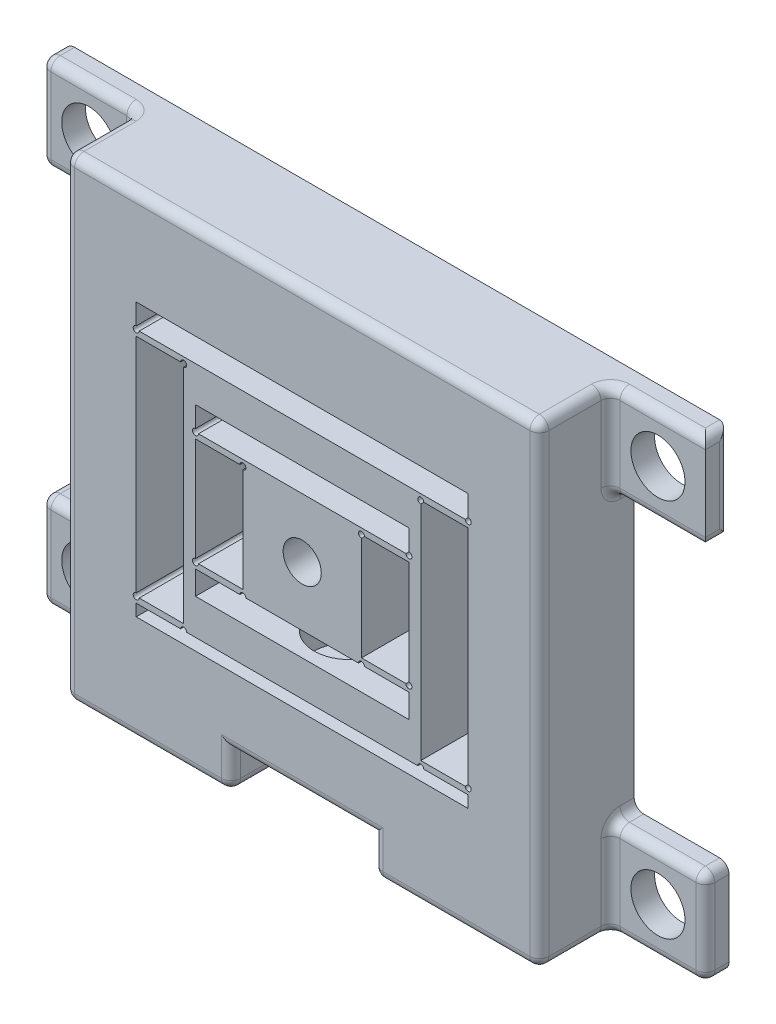
from build123d import *

# Parameters (mm, degrees)
SKETCH1_W           = 63.5
SKETCH1_H           = 63.5
BOSS_EXTRUDE1_DEPTH = 12.7
SKETCH2_W           = 28.575
SKETCH2_H           = 22.225
SKETCH2_W_2         = 15.875
SKETCH2_H_2         = 15.875
CUT_EXTRUDE1_DEPTH  = 13.7
SKETCH3_W           = 44.45
SKETCH3_H           = 36.5125
SKETCH3_W_2         = 31.75
SKETCH3_H_2         = 31.75
CUT_EXTRUDE2_DEPTH  = 13.7
SKETCH4_W           = 6.35
SKETCH4_H           = 0.8
BOSS_EXTRUDE3_DEPTH = 12.7
SKETCH5_R           = 0.399999962
CUT_EXTRUDE3_DEPTH  = 13.7
SKETCH6_R           = 4.2164
CUT_EXTRUDE4_DEPTH  = 14.2875
CUT_EXTRUDE6_REACH  = 49.625
SKETCH8_R           = 4.7625
SKETCH10_R          = 2.5527
CUT_EXTRUDE8_DEPTH  = 13.7
CUT_EXTRUDE9_START  = -7.62
SKETCH12_R          = 1.1303
CUT_EXTRUDE9_DEPTH  = 31.070640303
SKETCH19_W          = 12.7
SKETCH19_H          = 12.7
BOSS_EXTRUDE4_DEPTH = 3.175
SKETCH9_R           = 3.6195
CUT_EXTRUDE7_DEPTH  = 13.7
FILLET3_R           = 1.27
SKETCH20_W          = 19.05
SKETCH20_H          = 12.7
CUT_EXTRUDE10_DEPTH = 5.08
FILLET4_R           = 1.27


with BuildPart() as part:
    # Sketch1 → Boss-Extrude1 (new body)
    with BuildSketch(Plane.XY):
        Rectangle(SKETCH1_W, SKETCH1_H)
    extrude(amount=BOSS_EXTRUDE1_DEPTH)

    # Sketch2 → Cut-Extrude1 (cut, through all)
    with BuildSketch(Plane.XY.offset(12.7)):
        Rectangle(SKETCH2_W, SKETCH2_H)
        Rectangle(SKETCH2_W_2, SKETCH2_H_2, mode=Mode.SUBTRACT)
    extrude(amount=-CUT_EXTRUDE1_DEPTH, mode=Mode.SUBTRACT)

    # Sketch3 → Cut-Extrude2 (cut, through all)
    with BuildSketch(Plane.XY.offset(12.7)):
        with Locations((0, 0.79375)):
            Rectangle(SKETCH3_W, SKETCH3_H)
        Rectangle(SKETCH3_W_2, SKETCH3_H_2, mode=Mode.SUBTRACT)
    extrude(amount=-CUT_EXTRUDE2_DEPTH, mode=Mode.SUBTRACT)

    # Sketch4 → Boss-Extrude3 (add)
    with BuildSketch(Plane.XY.offset(12.7)):
        with Locations((-11.1125, 7.5375)):
            Rectangle(SKETCH4_W, SKETCH4_H)
        with Locations((-19.05, 15.475)):
            Rectangle(SKETCH4_W, SKETCH4_H)
        with Locations((19.05, 15.475)):
            Rectangle(SKETCH4_W, SKETCH4_H)
        with Locations((11.1125, 7.5375)):
            Rectangle(SKETCH4_W, SKETCH4_H)
        with Locations((11.1125, -7.5375)):
            Rectangle(SKETCH4_W, SKETCH4_H)
        with Locations((19.05, -15.475)):
            Rectangle(SKETCH4_W, SKETCH4_H)
        with Locations((-19.05, -15.475)):
            Rectangle(SKETCH4_W, SKETCH4_H)
        with Locations((-11.1125, -7.5375)):
            Rectangle(SKETCH4_W, SKETCH4_H)
    extrude(amount=-BOSS_EXTRUDE3_DEPTH)

    # Sketch5 → Cut-Extrude3 (cut, through all)
    with BuildSketch(Plane.XY.offset(12.7)):
        with Locations((-22.225, 15.875)):
            Circle(SKETCH5_R)
        with Locations((-15.875, 15.075)):
            Circle(SKETCH5_R)
        with Locations((7.9375, 7.1375)):
            Circle(SKETCH5_R)
        with Locations((-14.2875, 7.9375)):
            Circle(SKETCH5_R)
        with Locations((-7.9375, 7.1375)):
            Circle(SKETCH5_R)
        with Locations((14.2875, 7.9375)):
            Circle(SKETCH5_R)
        with Locations((15.875, 15.075)):
            Circle(SKETCH5_R)
        with Locations((22.225, 15.875)):
            Circle(SKETCH5_R)
        with Locations((-7.9375, -7.9375)):
            Circle(SKETCH5_R)
        with Locations((-14.2875, -7.1375)):
            Circle(SKETCH5_R)
        with Locations((-22.225, -15.075)):
            Circle(SKETCH5_R)
        with Locations((-15.875, -15.875)):
            Circle(SKETCH5_R)
        with Locations((15.875, -15.875)):
            Circle(SKETCH5_R)
        with Locations((22.225, -15.075)):
            Circle(SKETCH5_R)
        with Locations((14.2875, -7.1375)):
            Circle(SKETCH5_R)
        with Locations((7.9375, -7.9375)):
            Circle(SKETCH5_R)
    extrude(amount=-CUT_EXTRUDE3_DEPTH, mode=Mode.SUBTRACT)

    # Sketch6 → Cut-Extrude4 (cut)
    with BuildSketch(Plane(origin=(0, -31.75, 0), x_dir=(-1, 0, 0), z_dir=(0, -1, 0))):
        with Locations((0, -6.35)):
            Circle(SKETCH6_R)
    extrude(amount=-CUT_EXTRUDE4_DEPTH, mode=Mode.SUBTRACT)

    # Sketch8 → Cut-Extrude6 (cut, up to next)
    with BuildSketch(Plane(origin=(0, -15.875, 0), x_dir=(-1, 0, 0), z_dir=(0, -1, 0)), mode=Mode.PRIVATE) as cut_extrude6_sk1:
        with Locations((0, -6.35)):
            Circle(SKETCH8_R)
    cut_extrude6_tool1 = extrude(cut_extrude6_sk1.sketch, amount=-CUT_EXTRUDE6_REACH, mode=Mode.PRIVATE) & part.part
    add(cut_extrude6_tool1.solids().sort_by_distance((0, -15.875, 6.35))[0], mode=Mode.SUBTRACT)

    # Sketch10 → Cut-Extrude8 (cut, through all)
    with BuildSketch(Plane.XY.offset(12.7)):
        Circle(SKETCH10_R)
    extrude(amount=-CUT_EXTRUDE8_DEPTH, mode=Mode.SUBTRACT)

    # Sketch12 → Cut-Extrude9 (cut)
    with BuildSketch(Plane(origin=(15.875, -15.875, 0), x_dir=(0, 0, -1), z_dir=(0.707106781, -0.707106781, 0)).offset(CUT_EXTRUDE9_START)):
        with Locations((-6.35, -11.020640303)):
            Circle(SKETCH12_R)
    cut_extrude9 = extrude(amount=CUT_EXTRUDE9_DEPTH, mode=Mode.SUBTRACT)

    # Mirror1: Cut-Extrude9 across plane
    add(cut_extrude9.mirror(Plane(origin=(0, 0, 0), x_dir=(0, 0, 1), z_dir=(1, 0, 0))), mode=Mode.SUBTRACT)

    # Sketch19 → Boss-Extrude4 (add)
    with BuildSketch(Plane(origin=(0, 0, 0), x_dir=(-1, 0, 0), z_dir=(0, 0, -1))):
        with Locations((38.1, -25.4)):
            Rectangle(SKETCH19_W, SKETCH19_H)
        with Locations((38.1, 25.4)):
            Rectangle(SKETCH19_W, SKETCH19_H)
        with Locations((-38.1, 25.4)):
            Rectangle(SKETCH19_W, SKETCH19_H)
        with Locations((-38.1, -25.4)):
            Rectangle(SKETCH19_W, SKETCH19_H)
    extrude(amount=-BOSS_EXTRUDE4_DEPTH)

    # Sketch9 → Cut-Extrude7 (cut, through all)
    with BuildSketch(Plane.XY.offset(12.7)):
        with Locations((-38.1, 25.4)):
            Circle(SKETCH9_R)
        with Locations((38.1, 25.4)):
            Circle(SKETCH9_R)
        with Locations((38.1, -25.4)):
            Circle(SKETCH9_R)
        with Locations((-38.1, -25.4)):
            Circle(SKETCH9_R)
    extrude(amount=-CUT_EXTRUDE7_DEPTH, mode=Mode.SUBTRACT)

    # Fillet3
    fillet3_edges = [part.edges().sort_by_distance(p)[0] for p in [
        (-31.75, -25.4, 3.175),
        (-38.1, -19.05, 3.175),
        (-31.75, -19.05, 1.5875),
        (-44.45, -25.4, 3.175),
        (-44.45, -19.05, 1.5875),
        (-38.1, -31.75, 3.175),
        (-44.45, -31.75, 1.5875),
        (-31.75, 25.4, 3.175),
        (-31.75, 19.05, 1.5875),
        (-38.1, 31.75, 3.175),
        (-44.45, 25.4, 3.175),
        (-44.45, 31.75, 1.5875),
        (-38.1, 19.05, 3.175),
        (-44.45, 19.05, 1.5875),
        (38.1, 31.75, 3.175),
        (44.45, 31.75, 1.5875),
        (31.75, 25.4, 3.175),
        (38.1, 19.05, 3.175),
        (31.75, 19.05, 1.5875),
        (44.45, 19.05, 1.5875),
        (44.45, 25.4, 0),
        (38.1, -19.05, 3.175),
        (44.45, -19.05, 1.5875),
        (31.75, -25.4, 3.175),
        (31.75, -19.05, 1.5875),
        (38.1, -31.75, 3.175),
        (44.45, -25.4, 3.175),
        (44.45, -31.75, 1.5875),
        (31.75, -31.75, 7.9375),
        (31.75, 31.75, 7.9375),
        (-31.75, 31.75, 7.9375),
        (-31.75, -31.75, 7.9375),
        (31.75, 0, 12.7),
        (0, 31.75, 12.7),
        (-31.75, 0, 12.7),
        (0, -31.75, 12.7),
    ]]
    fillet(fillet3_edges, radius=FILLET3_R)

    # Sketch20 → Cut-Extrude10 (cut)
    with BuildSketch(Plane(origin=(0, -31.75, 0), x_dir=(-1, 0, 0), z_dir=(0, -1, 0))):
        with Locations((0, -6.35)):
            Rectangle(SKETCH20_W, SKETCH20_H)
    extrude(amount=-CUT_EXTRUDE10_DEPTH, mode=Mode.SUBTRACT)

    # Fillet4
    fillet4_edges = [part.edges().sort_by_distance(p)[0] for p in [
        (9.525, -28.575, 12.7),
        (9.525, -31.75, 5.715),
        (-9.525, -31.75, 5.715),
        (0, -26.67, 12.7),
        (-9.525, -28.575, 12.7),
    ]]
    fillet(fillet4_edges, radius=FILLET4_R)


solid = part.part
